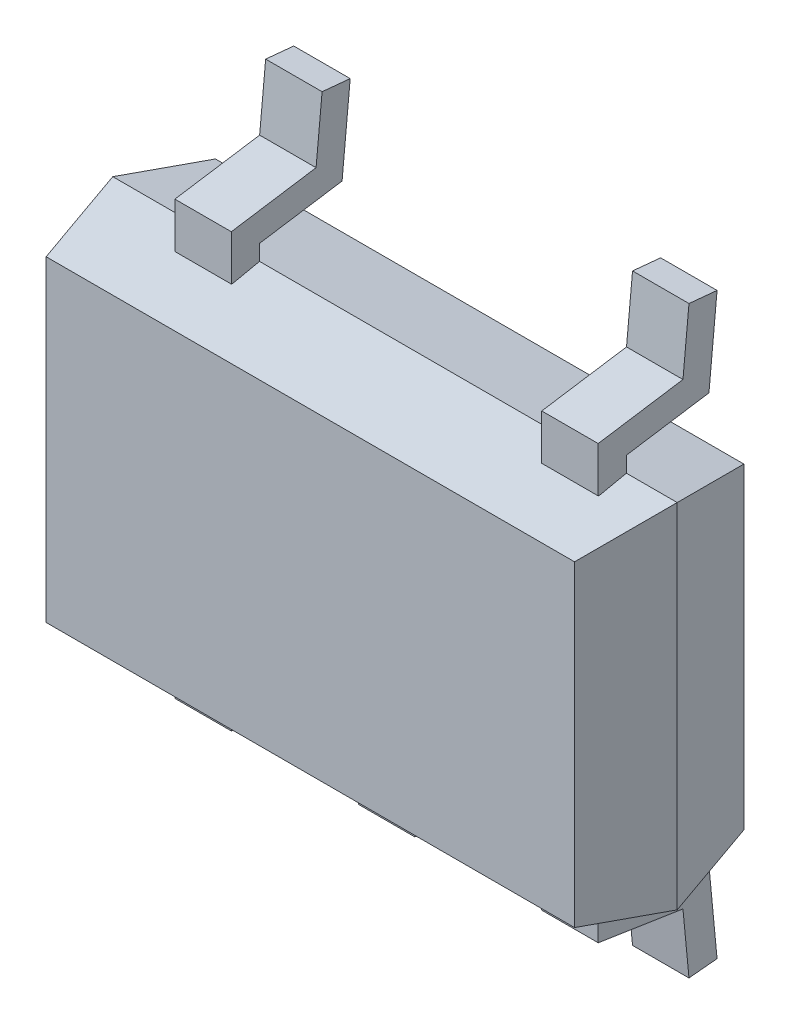
from build123d import *

# Parameters (mm, degrees)
SKETCH1_W              = 2
SKETCH1_H              = 1.25
BOSS_EXTRUDE1_DEPTH    = 0.3
BOSS_EXTRUDE1_TAPER    = 12
SKETCH2_W              = 2
SKETCH2_H              = 1.25
BOSS_EXTRUDE2_DEPTH    = 0.3
BOSS_EXTRUDE2_TAPER    = 12
EXTRUDE_THIN1_DEPTH    = 0.1
LPATTERN2_COUNT        = 3
LPATTERN2_PITCH        = 0.65
LPATTERN5_COUNT        = 2
LPATTERN5_PITCH        = 1.3
LPATTERN5_COPY_1_DEPTH = 0.1


with BuildPart() as part:
    # Sketch1 → Boss-Extrude1 (new body)
    with BuildSketch(Plane.XY):
        with Locations((1, 0.625)):
            Rectangle(SKETCH1_W, SKETCH1_H)
    extrude(amount=BOSS_EXTRUDE1_DEPTH, taper=BOSS_EXTRUDE1_TAPER)

    # Sketch2 → Boss-Extrude2 (add)
    with BuildSketch(Plane(origin=(0, 0, 0), x_dir=(-1, 0, 0), z_dir=(0, 0, -1))):
        with Locations((-1, 0.625)):
            Rectangle(SKETCH2_W, SKETCH2_H)
    extrude(amount=BOSS_EXTRUDE2_DEPTH, taper=BOSS_EXTRUDE2_TAPER)


with BuildPart() as body_2:
    # Sketch3 → Extrude-Thin1 (new body, symmetric)
    with BuildSketch(Plane(origin=(0.42, 0, 0), x_dir=(0, 0, -1), z_dir=(1, 0, 0))):
        Polygon((0, 0.019637055), (0, -0.055273318), (0.292471074, -0.100362945), (0.321223622, -0.400362945), (0.221679765, -0.40990341), (0.200349083, -0.187342106), (-0.1, -0.141037944), (-0.1, 0.019637055), align=None)
    extrude_thin1 = extrude(amount=EXTRUDE_THIN1_DEPTH, both=True)


with BuildPart() as part_1:
    add(part.part)

    # Mirror9: Extrude-Thin1 across plane
    add(extrude_thin1.mirror(Plane.ZX.offset(0.625)))

    # LPattern5: Extrude-Thin1 ×2
    with Locations(*[(i * LPATTERN5_PITCH, 0, 0) for i in range(1, LPATTERN5_COUNT)]):
        add(extrude_thin1)

    # LPattern5 copy 1 sketch → LPattern5 copy 1 (add, symmetric)
    with BuildSketch(Plane(origin=(1.72, 1.25, 0), x_dir=(0, 0, -1), z_dir=(1, 0, 0))):
        Polygon((0, -0.019637055), (0, 0.055273318), (0.292471074, 0.100362945), (0.321223622, 0.400362945), (0.221679765, 0.40990341), (0.200349083, 0.187342106), (-0.1, 0.141037944), (-0.1, -0.019637055), align=None)
    extrude(amount=LPATTERN5_COPY_1_DEPTH, both=True)


with BuildPart() as lpattern2_1:
    # LPattern2: Extrude-Thin1 ×3
    with Locations(*[(i * LPATTERN2_PITCH, 0, 0) for i in range(1, LPATTERN2_COUNT)]):
        add(extrude_thin1)


solid = Compound([body_2.part, part_1.part, lpattern2_1.part])
